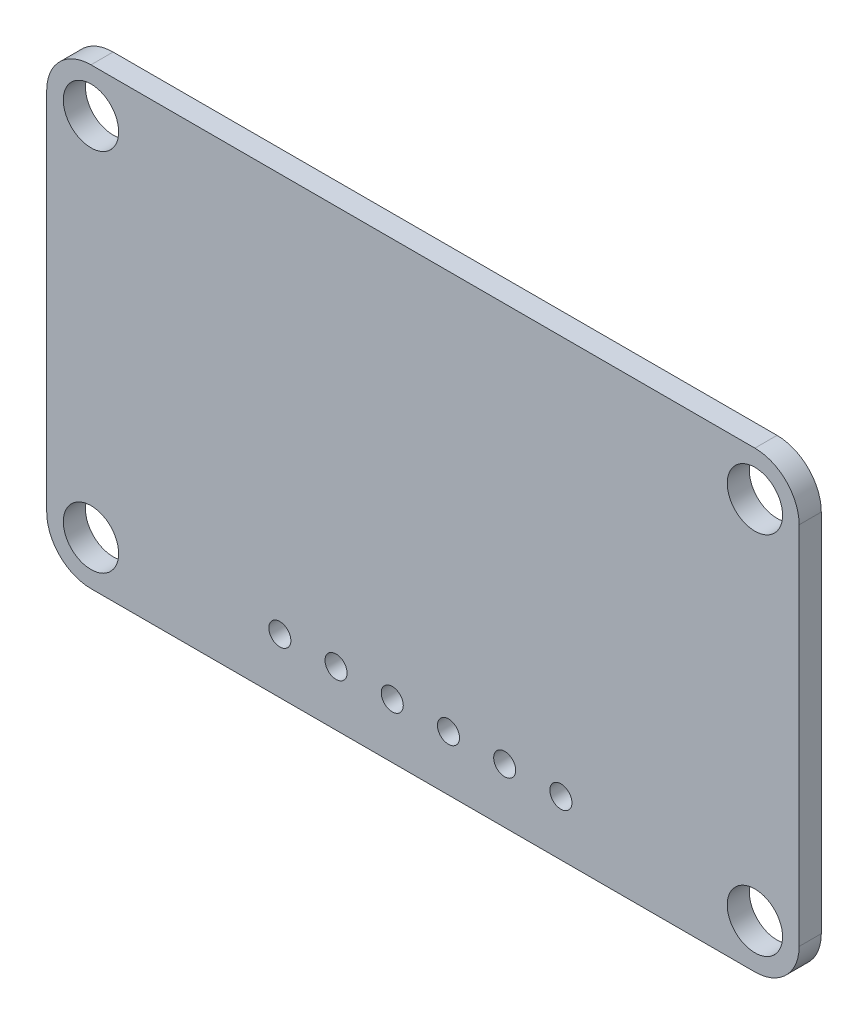
from build123d import *

# Parameters (mm, degrees)
SKETCH1_W               = 34
SKETCH1_H               = 20.5
COMPONENT_OUTLINE_DEPTH = 1
CUT_EXTRUDE1_REACH      = 3
SKETCH4_R               = 0.498272188
SKETCH5_R               = 1.25
CUT_EXTRUDE2_DEPTH      = 2
FILLET1_R               = 2


with BuildPart() as part:
    # Sketch1 → Component_Outline (new body)
    with BuildSketch(Plane.XY):
        with Locations((1.76, 0.09)):
            Rectangle(SKETCH1_W, SKETCH1_H)
    extrude(amount=COMPONENT_OUTLINE_DEPTH)

    # Sketch4 → Cut-Extrude1 (cut, up to next)
    with BuildSketch(Plane.XY.offset(1), mode=Mode.PRIVATE) as cut_extrude1_sk1:
        with Locations((-4.706120495, -7.675571956)):
            Circle(SKETCH4_R)
    cut_extrude1_tool1 = extrude(cut_extrude1_sk1.sketch, amount=-CUT_EXTRUDE1_REACH, mode=Mode.PRIVATE) & part.part
    add(cut_extrude1_tool1.solids().sort_by_distance((-4.70612, -7.675572, 1))[0], mode=Mode.SUBTRACT)
    # Sketch4 → Cut-Extrude1 (cut, up to next)
    with BuildSketch(Plane.XY.offset(1), mode=Mode.PRIVATE) as cut_extrude1_sk2:
        with Locations((-2.166120495, -7.675571956)):
            Circle(SKETCH4_R)
    cut_extrude1_tool2 = extrude(cut_extrude1_sk2.sketch, amount=-CUT_EXTRUDE1_REACH, mode=Mode.PRIVATE) & part.part
    add(cut_extrude1_tool2.solids().sort_by_distance((-2.16612, -7.675572, 1))[0], mode=Mode.SUBTRACT)
    # Sketch4 → Cut-Extrude1 (cut, up to next)
    with BuildSketch(Plane.XY.offset(1), mode=Mode.PRIVATE) as cut_extrude1_sk3:
        with Locations((0.373879505, -7.675571956)):
            Circle(SKETCH4_R)
    cut_extrude1_tool3 = extrude(cut_extrude1_sk3.sketch, amount=-CUT_EXTRUDE1_REACH, mode=Mode.PRIVATE) & part.part
    add(cut_extrude1_tool3.solids().sort_by_distance((0.37388, -7.675572, 1))[0], mode=Mode.SUBTRACT)
    # Sketch4 → Cut-Extrude1 (cut, up to next)
    with BuildSketch(Plane.XY.offset(1), mode=Mode.PRIVATE) as cut_extrude1_sk4:
        with Locations((2.913879505, -7.675571956)):
            Circle(SKETCH4_R)
    cut_extrude1_tool4 = extrude(cut_extrude1_sk4.sketch, amount=-CUT_EXTRUDE1_REACH, mode=Mode.PRIVATE) & part.part
    add(cut_extrude1_tool4.solids().sort_by_distance((2.91388, -7.675572, 1))[0], mode=Mode.SUBTRACT)
    # Sketch4 → Cut-Extrude1 (cut, up to next)
    with BuildSketch(Plane.XY.offset(1), mode=Mode.PRIVATE) as cut_extrude1_sk5:
        with Locations((5.453879505, -7.675571956)):
            Circle(SKETCH4_R)
    cut_extrude1_tool5 = extrude(cut_extrude1_sk5.sketch, amount=-CUT_EXTRUDE1_REACH, mode=Mode.PRIVATE) & part.part
    add(cut_extrude1_tool5.solids().sort_by_distance((5.45388, -7.675572, 1))[0], mode=Mode.SUBTRACT)
    # Sketch4 → Cut-Extrude1 (cut, up to next)
    with BuildSketch(Plane.XY.offset(1), mode=Mode.PRIVATE) as cut_extrude1_sk6:
        with Locations((7.993879505, -7.675571956)):
            Circle(SKETCH4_R)
    cut_extrude1_tool6 = extrude(cut_extrude1_sk6.sketch, amount=-CUT_EXTRUDE1_REACH, mode=Mode.PRIVATE) & part.part
    add(cut_extrude1_tool6.solids().sort_by_distance((7.99388, -7.675572, 1))[0], mode=Mode.SUBTRACT)

    # Sketch5 → Cut-Extrude2 (cut, through all)
    with BuildSketch(Plane.XY.offset(1)):
        with Locations((-13.24, 8.34)):
            Circle(SKETCH5_R)
        with Locations((16.76, 8.34)):
            Circle(SKETCH5_R)
        with Locations((16.76, -8.16)):
            Circle(SKETCH5_R)
        with Locations((-13.24, -8.16)):
            Circle(SKETCH5_R)
    extrude(amount=-CUT_EXTRUDE2_DEPTH, mode=Mode.SUBTRACT)

    # Fillet1
    fillet1_edges = [part.edges().sort_by_distance(p)[0] for p in [
        (-15.24, 10.34, 0.5),
        (18.76, 10.34, 0.5),
        (18.76, -10.16, 0.5),
        (-15.24, -10.16, 0.5),
    ]]
    fillet(fillet1_edges, radius=FILLET1_R)


solid = part.part
